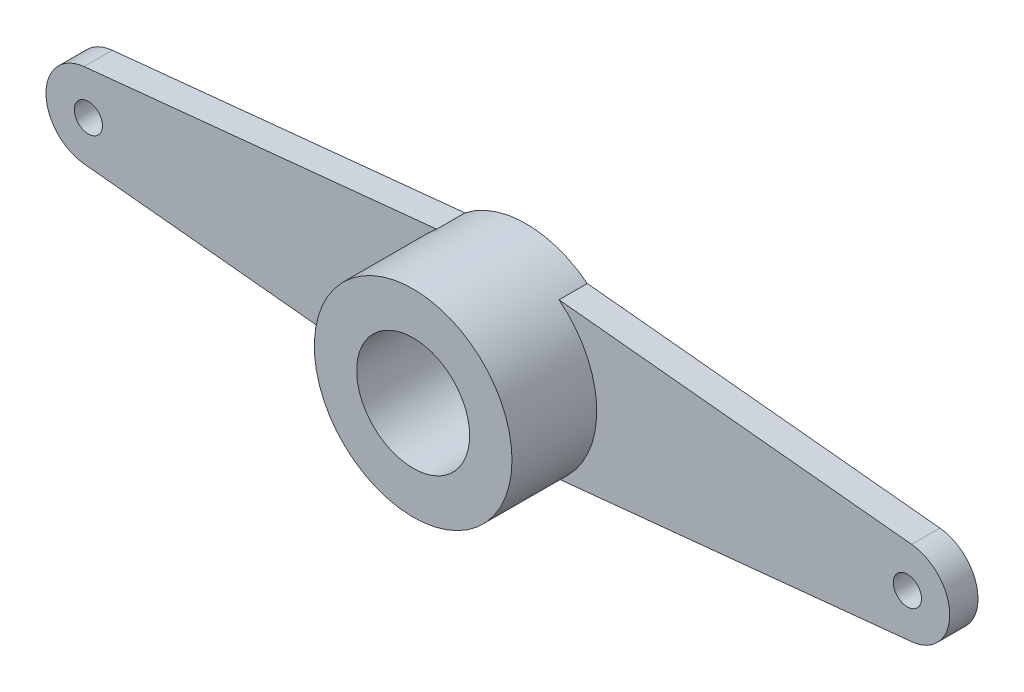
from build123d import *

# Parameters (mm, degrees)
SKETCH_1_R      = 2
SKETCH_1_R_2    = 0.5
EXTRUDE_2_DEPTH = 1
SKETCH_2_R      = 3.5
SKETCH_2_R_2    = 2
EXTRUDE_3_DEPTH = 3


with BuildPart() as part:
    # 草图1 → 凸台-拉伸2 (new body)
    with BuildSketch(Plane.XY):
        with BuildLine():
            Line((14.650323726, 1.492448585), (2.165063509, 2.75))
            ThreePointArc((2.165063509, 2.75), (-3.5, 0), (2.165063509, -2.75))
            Line((2.165063509, -2.75), (14.650323726, -1.492448585))
            ThreePointArc((14.650323726, -1.492448585), (16, 0), (14.650323726, 1.492448585))
        make_face()
        Circle(SKETCH_1_R, mode=Mode.SUBTRACT)
        with Locations((14.5, 0)):
            Circle(SKETCH_1_R_2, mode=Mode.SUBTRACT)
    extrude_2 = extrude(amount=EXTRUDE_2_DEPTH)

    # 草图2 → 凸台-拉伸3 (add)
    with BuildSketch(Plane.XY.offset(1)):
        Circle(SKETCH_2_R)
        Circle(SKETCH_2_R_2, mode=Mode.SUBTRACT)
    extrude(amount=EXTRUDE_3_DEPTH)

    # 镜向1: 凸台-拉伸2 across plane
    add(extrude_2.mirror(Plane(origin=(0, 0, 0), x_dir=(0, 0, 1), z_dir=(1, 0, 0))))


solid = part.part
